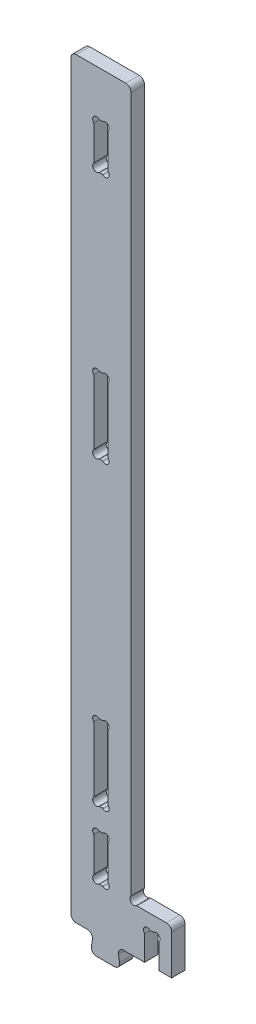
from build123d import *

# Parameters (mm, degrees)
BOSS_EXTRUDE1_DEPTH = 18
CUT_EXTRUDE1_DEPTH  = 19
CUT_EXTRUDE2_DEPTH  = 19
CUT_EXTRUDE3_DEPTH  = 19
LPATTERN1_COUNT     = 2
LPATTERN1_PITCH     = 400
FILLET1_R           = 7


with BuildPart() as part:
    # Sketch1 → Boss-Extrude1 (new body)
    with BuildSketch(Plane.XY):
        with BuildLine():
            Line((0, 0), (30, 0))
            Line((30, 0), (26, -25))
            Line((26, -25), (66, -25))
            Line((66, -25), (62, 0))
            Line((62, 0), (134, 0))
            Line((134, 0), (134, 60))
            Line((134, 60), (87.987761491, 60))
            ThreePointArc((87.987761491, 60), (87.206612206, 59.874827529), (86.503685629, 59.511844635))
            ThreePointArc((86.503685629, 59.511844635), (80, 60), (79.511844635, 66.503685629))
            ThreePointArc((79.511844635, 66.503685629), (79.874827529, 67.206612206), (80, 67.987761491))
            Line((80, 67.987761491), (80, 1000))
            Line((80, 1000), (0, 1000))
            Line((0, 1000), (0, 0))
        make_face()
    extrude(amount=BOSS_EXTRUDE1_DEPTH)

    # Sketch2 → Cut-Extrude1 (cut, through all)
    with BuildSketch(Plane.XY):
        with BuildLine():
            Line((49.5, 642.748771852), (49.5, 557.251228148))
            ThreePointArc((49.5, 557.251228148), (49.599672829, 556.660561143), (49.88765279, 556.135309084))
            ThreePointArc((49.88765279, 556.135309084), (49.5, 549.5), (42.864690916, 549.11234721))
            ThreePointArc((42.864690916, 549.11234721), (42.339438857, 549.400327171), (41.748771852, 549.5))
            Line((41.748771852, 549.5), (38.251228148, 549.5))
            ThreePointArc((38.251228148, 549.5), (37.660561143, 549.400327171), (37.135309084, 549.11234721))
            ThreePointArc((37.135309084, 549.11234721), (30.5, 549.5), (30.11234721, 556.135309084))
            ThreePointArc((30.11234721, 556.135309084), (30.400327171, 556.660561143), (30.5, 557.251228148))
            Line((30.5, 557.251228148), (30.5, 642.748771852))
            ThreePointArc((30.5, 642.748771852), (30.400327171, 643.339438857), (30.11234721, 643.864690916))
            ThreePointArc((30.11234721, 643.864690916), (30.5, 650.5), (37.135309084, 650.88765279))
            ThreePointArc((37.135309084, 650.88765279), (37.660561143, 650.599672829), (38.251228148, 650.5))
            Line((38.251228148, 650.5), (41.748771852, 650.5))
            ThreePointArc((41.748771852, 650.5), (42.339438857, 650.599672829), (42.864690916, 650.88765279))
            ThreePointArc((42.864690916, 650.88765279), (49.5, 650.5), (49.88765279, 643.864690916))
            ThreePointArc((49.88765279, 643.864690916), (49.599672829, 643.339438857), (49.5, 642.748771852))
        make_face()
    cut_extrude1 = extrude(amount=CUT_EXTRUDE1_DEPTH, mode=Mode.SUBTRACT)

    # Sketch3 → Cut-Extrude2 (cut, through all)
    with BuildSketch(Plane.XY):
        with BuildLine():
            Line((98, 0), (117, 0))
            Line((117, 0), (117, 32.748771852))
            ThreePointArc((117, 32.748771852), (117.099672829, 33.339438857), (117.38765279, 33.864690916))
            ThreePointArc((117.38765279, 33.864690916), (117, 40.5), (110.364690916, 40.88765279))
            ThreePointArc((110.364690916, 40.88765279), (109.839438857, 40.599672829), (109.248771852, 40.5))
            Line((109.248771852, 40.5), (105.751228148, 40.5))
            ThreePointArc((105.751228148, 40.5), (105.160561143, 40.599672829), (104.635309084, 40.88765279))
            ThreePointArc((104.635309084, 40.88765279), (98, 40.5), (97.61234721, 33.864690916))
            ThreePointArc((97.61234721, 33.864690916), (97.900327171, 33.339438857), (98, 32.748771852))
            Line((98, 32.748771852), (98, 0))
        make_face()
    extrude(amount=CUT_EXTRUDE2_DEPTH, mode=Mode.SUBTRACT)

    # Sketch4 → Cut-Extrude3 (cut, through all)
    with BuildSketch(Plane.XY):
        with BuildLine():
            Line((49.5, 113.248771852), (49.5, 67.751228148))
            ThreePointArc((49.5, 67.751228148), (49.599672829, 67.160561143), (49.88765279, 66.635309084))
            ThreePointArc((49.88765279, 66.635309084), (49.5, 60), (42.864690916, 59.61234721))
            ThreePointArc((42.864690916, 59.61234721), (42.339438857, 59.900327171), (41.748771852, 60))
            Line((41.748771852, 60), (38.251228148, 60))
            ThreePointArc((38.251228148, 60), (37.660561143, 59.900327171), (37.135309084, 59.61234721))
            ThreePointArc((37.135309084, 59.61234721), (30.5, 60), (30.11234721, 66.635309084))
            ThreePointArc((30.11234721, 66.635309084), (30.400327171, 67.160561143), (30.5, 67.751228148))
            Line((30.5, 67.751228148), (30.5, 113.248771852))
            ThreePointArc((30.5, 113.248771852), (30.400327171, 113.839438857), (30.11234721, 114.364690916))
            ThreePointArc((30.11234721, 114.364690916), (30.5, 121), (37.135309084, 121.38765279))
            ThreePointArc((37.135309084, 121.38765279), (37.660561143, 121.099672829), (38.251228148, 121))
            Line((38.251228148, 121), (41.748771852, 121))
            ThreePointArc((41.748771852, 121), (42.339438857, 121.099672829), (42.864690916, 121.38765279))
            ThreePointArc((42.864690916, 121.38765279), (49.5, 121), (49.88765279, 114.364690916))
            ThreePointArc((49.88765279, 114.364690916), (49.599672829, 113.839438857), (49.5, 113.248771852))
        make_face()
        with BuildLine():
            Line((38.251228148, 879.5), (41.748771852, 879.5))
            ThreePointArc((41.748771852, 879.5), (42.339438857, 879.400327171), (42.864690916, 879.11234721))
            ThreePointArc((42.864690916, 879.11234721), (49.5, 879.5), (49.88765279, 886.135309084))
            ThreePointArc((49.88765279, 886.135309084), (49.599672829, 886.660561143), (49.5, 887.251228148))
            Line((49.5, 887.251228148), (49.5, 932.748771852))
            ThreePointArc((49.5, 932.748771852), (49.599672829, 933.339438857), (49.88765279, 933.864690916))
            ThreePointArc((49.88765279, 933.864690916), (49.5, 940.5), (42.864690916, 940.88765279))
            ThreePointArc((42.864690916, 940.88765279), (42.339438857, 940.599672829), (41.748771852, 940.5))
            Line((41.748771852, 940.5), (38.251228148, 940.5))
            ThreePointArc((38.251228148, 940.5), (37.660561143, 940.599672829), (37.135309084, 940.88765279))
            ThreePointArc((37.135309084, 940.88765279), (30.5, 940.5), (30.11234721, 933.864690916))
            ThreePointArc((30.11234721, 933.864690916), (30.400327171, 933.339438857), (30.5, 932.748771852))
            Line((30.5, 932.748771852), (30.5, 887.251228148))
            ThreePointArc((30.5, 887.251228148), (30.400327171, 886.660561143), (30.11234721, 886.135309084))
            ThreePointArc((30.11234721, 886.135309084), (30.5, 879.5), (37.135309084, 879.11234721))
            ThreePointArc((37.135309084, 879.11234721), (37.660561143, 879.400327171), (38.251228148, 879.5))
        make_face()
    extrude(amount=CUT_EXTRUDE3_DEPTH, mode=Mode.SUBTRACT)

    # LPattern1: Cut-Extrude1 ×2
    with Locations(*[(0, -i * LPATTERN1_PITCH, 0) for i in range(1, LPATTERN1_COUNT)]):
        add(cut_extrude1, mode=Mode.SUBTRACT)

    # Fillet1
    fillet1_edges = [part.edges().sort_by_distance(p)[0] for p in [
        (0, 0, 9),
        (0, 1000, 9),
        (80, 1000, 9),
        (134, 60, 9),
        (62, 0, 9),
        (66, -25, 9),
        (26, -25, 9),
        (30, 0, 9),
    ]]
    fillet(fillet1_edges, radius=FILLET1_R)


solid = part.part
